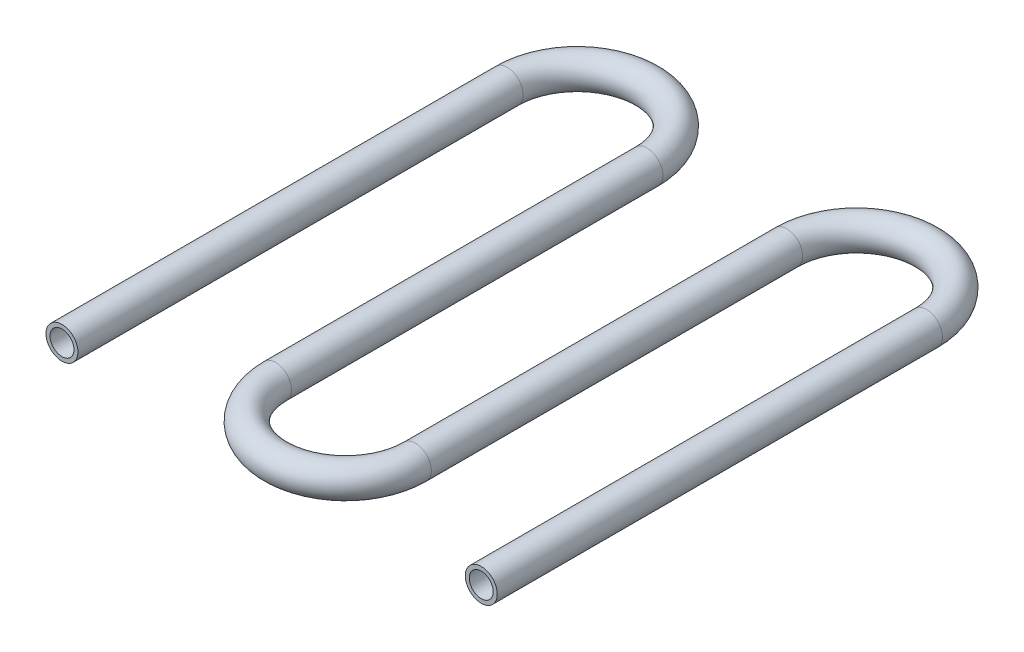
from build123d import *

# Parameters (mm, degrees)
SKETCH3_R   = 4
SKETCH3_R_2 = 3


with BuildPart() as part:
    # Sweep1: sweep along a path in Sketch2
    with BuildLine(Plane(origin=(0, 0, 0), x_dir=(1, 0, 0), z_dir=(0, 1, 0))) as sweep1_path:
        Line((87.5, -65), (87.5, 46.5))
        ThreePointArc((87.5, 46.5), (70, 64), (52.5, 46.5))
        Line((52.5, 46.5), (52.5, -46.5))
        ThreePointArc((52.5, -46.5), (35, -64), (17.5, -46.5))
        Line((17.5, -46.5), (17.5, 46.5))
        ThreePointArc((17.5, 46.5), (0, 64), (-17.5, 46.5))
        Line((-17.5, 46.5), (-17.5, -65))
    # Sketch3 → Sweep1 (sweep)
    with BuildSketch(Plane.XY.offset(65)):
        with Locations((-17.5, 0)):
            Circle(SKETCH3_R)
        with Locations((-17.5, 0)):
            Circle(SKETCH3_R_2, mode=Mode.SUBTRACT)
    sweep(path=sweep1_path.line)


solid = part.part
